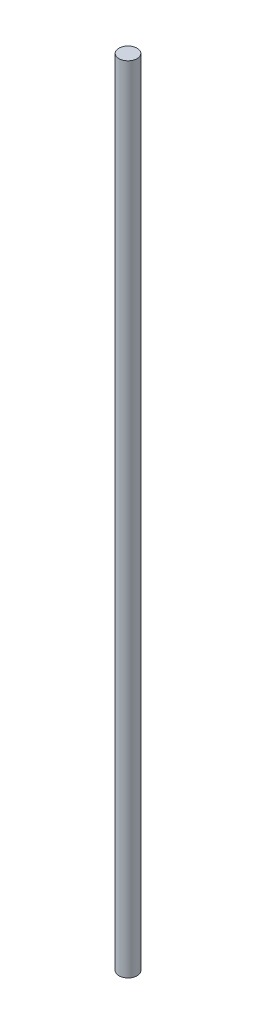
from build123d import *

# Parameters (mm, degrees)
SKETCH1_W = 4
SKETCH1_H = 350


with BuildPart() as part:
    # Sketch1 → Revolve1 (revolve)
    with BuildSketch(Plane.XY):
        with Locations((2, 175)):
            Rectangle(SKETCH1_W, SKETCH1_H)
    revolve(axis=Axis((0, 350, 0), (0, -1, 0)))


solid = part.part
